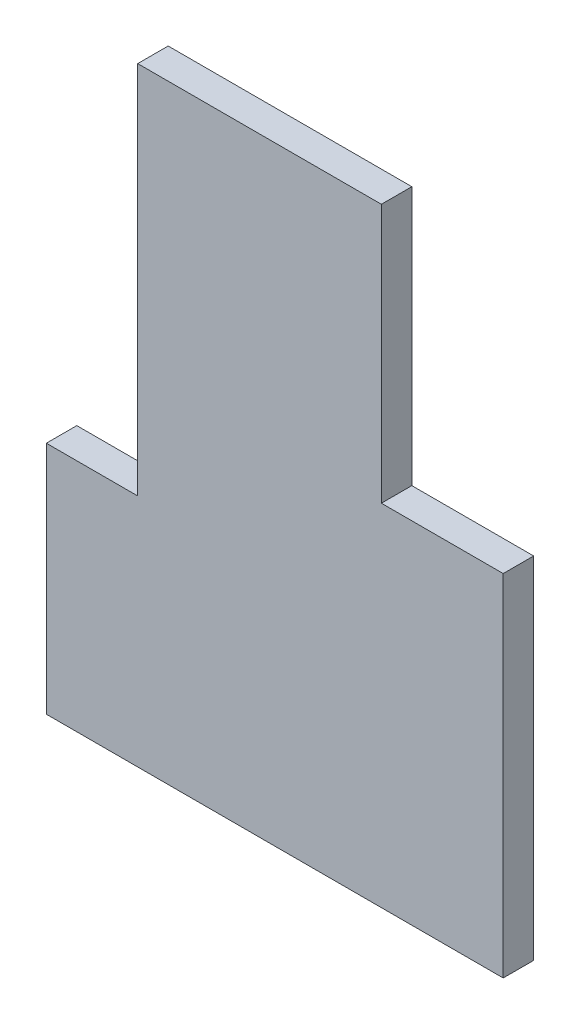
from build123d import *

# Parameters (mm, degrees)
BOSS_EXTRUDE1_DEPTH = 10


with BuildPart() as part:
    # Sketch2 → Boss-Extrude1 (new body)
    with BuildSketch(Plane.XY):
        Polygon((-35.455650915, -20.73429878), (114.544349085, -20.73429878), (114.544349085, 94.26570122), (74.544349085, 94.26570122), (74.544349085, 179.26570122), (-5.455650915, 179.26570122), (-5.455650915, 56.329537329), (-35.455650915, 56.329537329), align=None)
    extrude(amount=BOSS_EXTRUDE1_DEPTH)


solid = part.part
